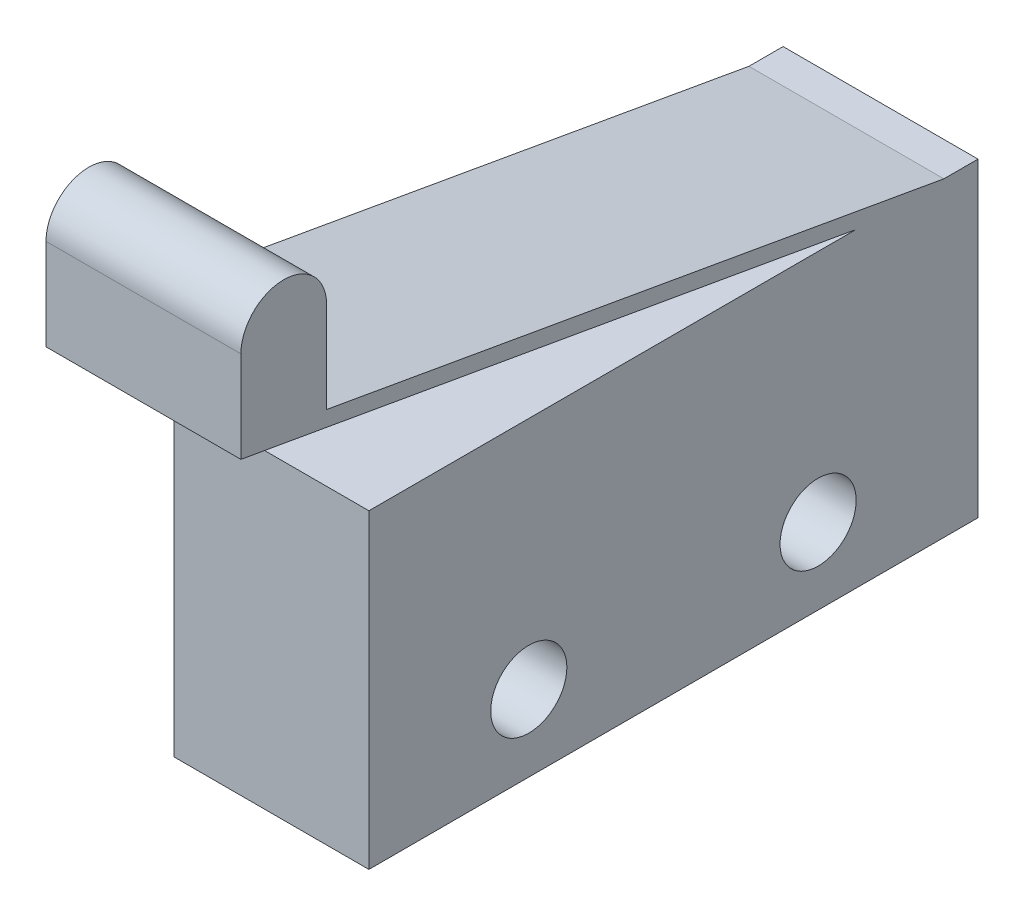
from build123d import *

# Parameters (mm, degrees)
SKETCH_1_R      = 1.25
EXTRUDE_1_DEPTH = 6.4


with BuildPart() as part:
    # 草图1 → 凸台-拉伸1 (new body)
    with BuildSketch(Plane(origin=(0, 0, 0), x_dir=(0, 0, -1), z_dir=(1, 0, 0))):
        with BuildLine():
            Line((-10, 10.970845222), (6, 10.970845222))
            Line((6, 10.970845222), (-14.202813689, 14.533146362))
            Line((-14.202813689, 14.533146362), (-14.202813689, 17.533146362))
            ThreePointArc((-14.202813689, 17.533146362), (-12.796398802, 18.939561248), (-11.389983916, 17.533146362))
            Line((-11.389983916, 17.533146362), (-11.389983916, 14.544881886))
            Line((-11.389983916, 14.544881886), (8.879385242, 10.970845222))
            Line((8.879385242, 10.970845222), (10, 10.970845222))
            Line((10, 10.970845222), (10, 0.770845222))
            Line((10, 0.770845222), (-10, 0.770845222))
            Line((-10, 0.770845222), (-10, 10.970845222))
        make_face()
        with Locations((-4.75, 3.270845222)):
            Circle(SKETCH_1_R, mode=Mode.SUBTRACT)
        with Locations((4.75, 3.270845222)):
            Circle(SKETCH_1_R, mode=Mode.SUBTRACT)
    extrude(amount=EXTRUDE_1_DEPTH)


solid = part.part
